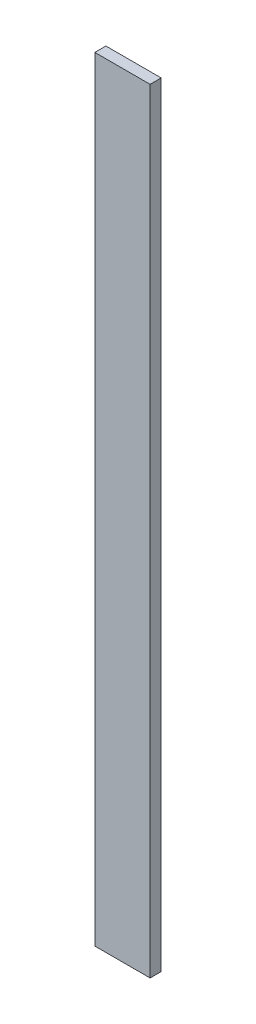
from build123d import *

# Parameters (mm, degrees)
SKIZZE2_W                       = 25
SKIZZE2_H                       = 5
AUFSATZ_LINEAR_AUSTRAGEN1_DEPTH = 175


with BuildPart() as part:
    # Skizze2 → Aufsatz-Linear austragen1 (new body, symmetric)
    with BuildSketch(Plane(origin=(0, 0, 0), x_dir=(1, 0, 0), z_dir=(0, 1, 0))):
        with Locations((48.825912394, -2.5)):
            Rectangle(SKIZZE2_W, SKIZZE2_H)
    extrude(amount=AUFSATZ_LINEAR_AUSTRAGEN1_DEPTH, both=True)


solid = part.part
